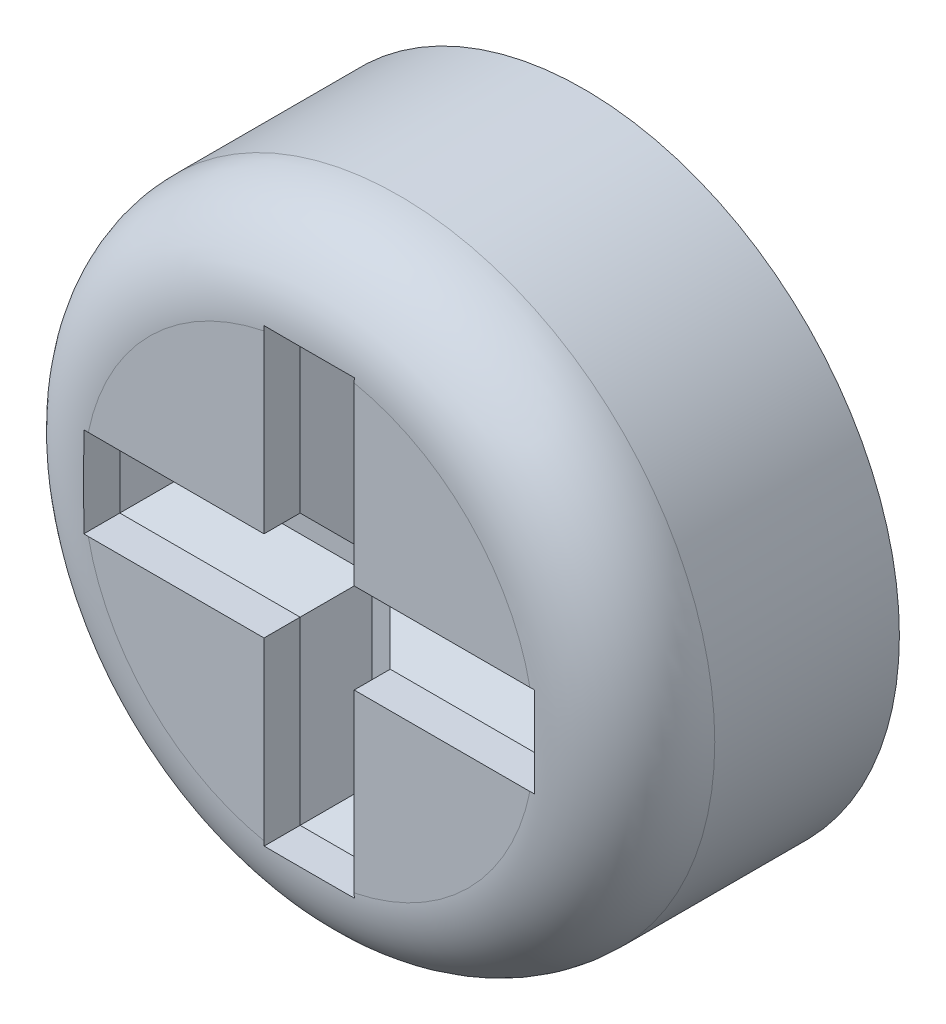
from build123d import *

# Parameters (mm, degrees)
SKETCH1_R          = 1.75
EXTRUDE1_DEPTH     = 1.524
FILLET1_R          = 0.5
CUT_EXTRUDE2_DEPTH = 0.4
CHAMFER1_SIZE      = 0.2


with BuildPart() as part:
    # Sketch1 → Extrude1 (new body)
    with BuildSketch(Plane.XY):
        Circle(SKETCH1_R)
    extrude(amount=EXTRUDE1_DEPTH)

    # Fillet1
    fillet1_edges = [part.edges().sort_by_distance(p)[0] for p in [
        (-1.75, 0, 1.524),
    ]]
    fillet(fillet1_edges, radius=FILLET1_R)

    # Sketch2 → Cut-Extrude2 (cut)
    with BuildSketch(Plane.XY.offset(1.524)):
        Polygon((0.25, -0.25), (0.25, -1.25), (-0.25, -1.25), (-0.25, -0.25), (-1.25, -0.25), (-1.25, 0.25), (-0.25, 0.25), (-0.25, 1.25), (0.25, 1.25), (0.25, 0.25), (1.25, 0.25), (1.25, -0.25), align=None)
    extrude(amount=-CUT_EXTRUDE2_DEPTH, mode=Mode.SUBTRACT)

    # Chamfer1
    chamfer1_edges = [part.edges().sort_by_distance(p)[0] for p in [
        (0.75, 0.25, 1.124),
        (0.25, -0.75, 1.124),
        (0, -1.25, 1.124),
        (-0.25, -0.75, 1.124),
        (-0.75, -0.25, 1.124),
        (-1.25, 0, 1.124),
        (-0.75, 0.25, 1.124),
        (-0.25, 0.75, 1.124),
        (0, 1.25, 1.124),
        (0.25, 0.75, 1.124),
        (1.25, 0, 1.124),
        (0.75, -0.25, 1.124),
    ]]
    chamfer(chamfer1_edges, length=CHAMFER1_SIZE)


solid = part.part
